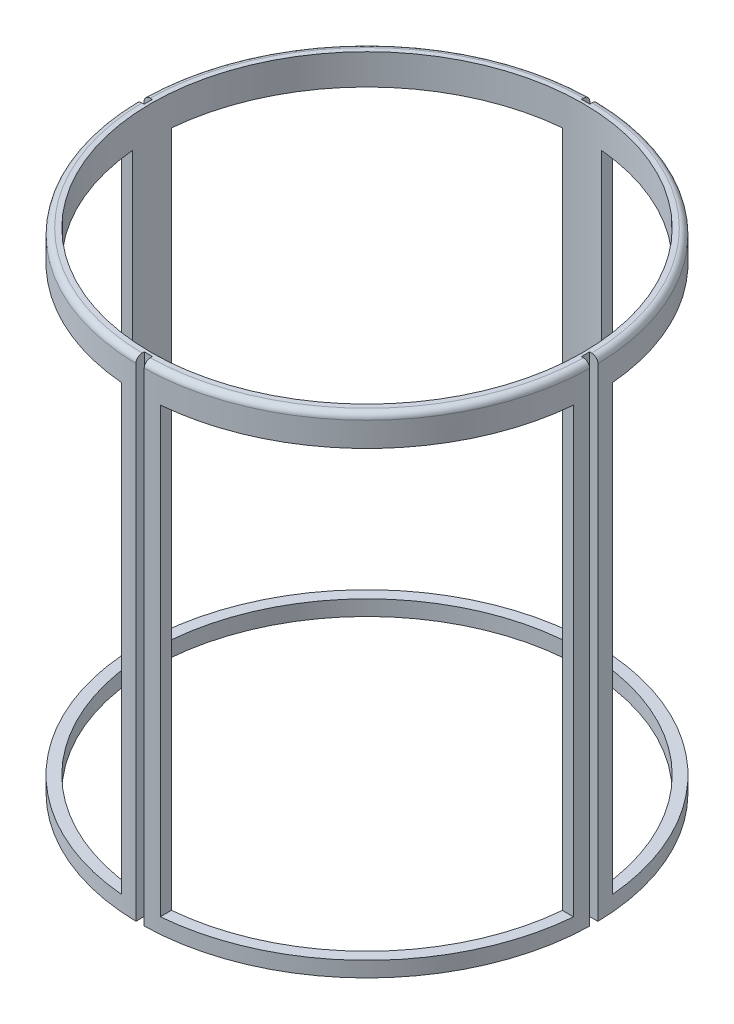
from build123d import *

# Parameters (mm, degrees)
SKETCH1_R           = 94.2975
SKETCH1_R_2         = 89.662
BOSS_EXTRUDE1_DEPTH = 203.2
SKETCH5_W           = 3.429
SKETCH5_H           = 5.08
SKETCH5_W_2         = 5.08
SKETCH5_H_2         = 3.429
CUT_EXTRUDE1_DEPTH  = 203.2
CUT_EXTRUDE2_START  = -12.7
CUT_EXTRUDE2_DEPTH  = 184.15
CIRPATTERN1_COUNT   = 4
FILLET1_R           = 2.54


with BuildPart() as part:
    # Sketch1 → Boss-Extrude1 (new body)
    with BuildSketch(Plane(origin=(0, 0, 0), x_dir=(1, 0, 0), z_dir=(0, 1, 0))):
        Circle(SKETCH1_R)
        Circle(SKETCH1_R_2, mode=Mode.SUBTRACT)
    extrude(amount=-BOSS_EXTRUDE1_DEPTH)

    # Sketch5 → Cut-Extrude1 (cut)
    with BuildSketch(Plane(origin=(0, 0, 0), x_dir=(1, 0, 0), z_dir=(0, 1, 0))):
        with Locations((0, 93.360875)):
            Rectangle(SKETCH5_W, SKETCH5_H)
        with Locations((0, -93.360875)):
            Rectangle(SKETCH5_W, SKETCH5_H)
        with Locations((-93.360875, -0.0635)):
            Rectangle(SKETCH5_W_2, SKETCH5_H_2)
        with Locations((93.360875, -0.0635)):
            Rectangle(SKETCH5_W_2, SKETCH5_H_2)
    extrude(amount=-CUT_EXTRUDE1_DEPTH, mode=Mode.SUBTRACT)

    # Sketch7 → Cut-Extrude2 (cut)
    with BuildSketch(Plane(origin=(0, 0, 0), x_dir=(1, 0, 0), z_dir=(0, 1, 0)).offset(CUT_EXTRUDE2_START)):
        with BuildLine():
            Line((89.292832075, -8.128), (93.946549283, -8.128))
            ThreePointArc((93.946549283, -8.128), (66.655864041, -66.700931742), (8.0645, -93.952021511))
            Line((8.0645, -93.952021511), (8.0645, -89.298589484))
            ThreePointArc((8.0645, -89.298589484), (63.378061476, -63.423146938), (89.292832075, -8.128))
        make_face()
    cut_extrude2 = extrude(amount=-CUT_EXTRUDE2_DEPTH, mode=Mode.SUBTRACT)

    # CirPattern1: Cut-Extrude2 ×4 about axis
    cirpattern1_axis = Axis((0, 0, 0), (0, 1, 0))
    for i in range(1, CIRPATTERN1_COUNT):
        add(cut_extrude2.rotate(cirpattern1_axis, i * 360 / CIRPATTERN1_COUNT), mode=Mode.SUBTRACT)

    # Fillet1
    fillet1_edges = [part.edges().sort_by_distance(p)[0] for p in [
        (66.700852134, 0, -66.655943702),
        (-66.700852134, 0, -66.655943702),
        (-66.655943427, 0, 66.700852409),
        (66.655943427, 0, 66.700852409),
    ]]
    fillet(fillet1_edges, radius=FILLET1_R)


solid = part.part
